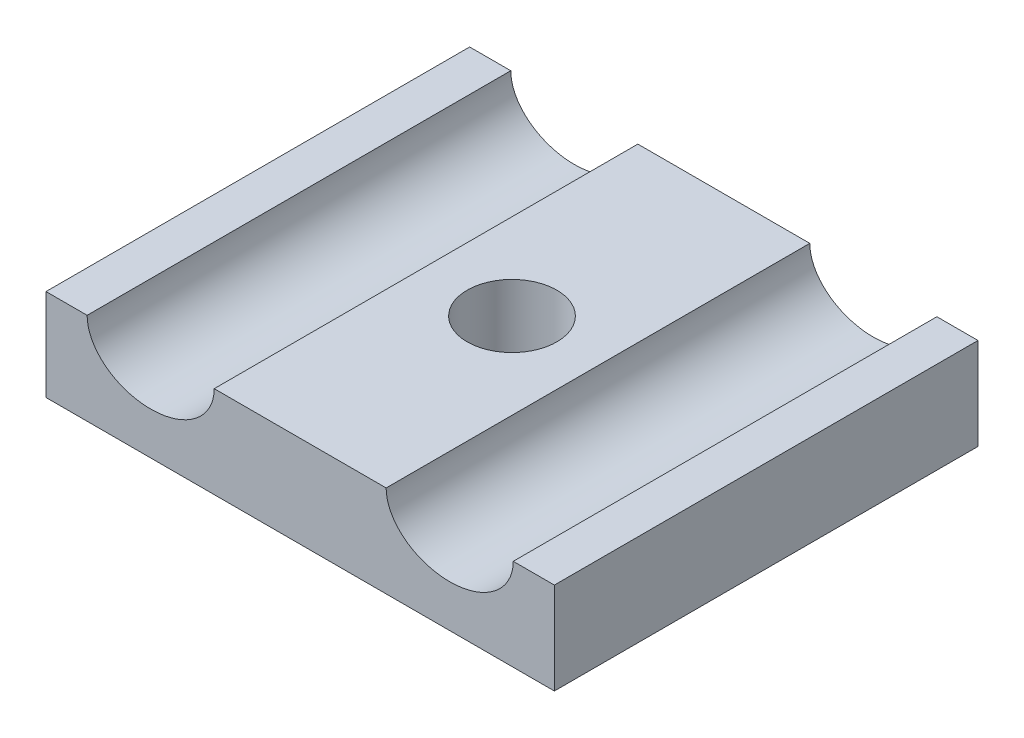
from build123d import *

# Parameters (mm, degrees)
SKETCH1_W           = 36
SKETCH1_H           = 30
BOSS_EXTRUDE1_DEPTH = 6.5
SKETCH2_R           = 3.175
CUT_EXTRUDE1_DEPTH  = 5
SKETCH3_RX          = 4.5
SKETCH3_RY          = 3.5
CUT_EXTRUDE3_DEPTH  = 30


with BuildPart() as part:
    # Sketch1 → Boss-Extrude1 (new body)
    with BuildSketch(Plane(origin=(0, 0, 0), x_dir=(1, 0, 0), z_dir=(0, 1, 0))):
        with Locations((-18, -15)):
            Rectangle(SKETCH1_W, SKETCH1_H)
    extrude(amount=BOSS_EXTRUDE1_DEPTH)

    # Sketch2 → Cut-Extrude1 (cut)
    with BuildSketch(Plane(origin=(0, 6.5, 0), x_dir=(1, 0, 0), z_dir=(0, 1, 0))):
        with Locations((-18, -15)):
            Circle(SKETCH2_R)
    extrude(amount=-CUT_EXTRUDE1_DEPTH, mode=Mode.SUBTRACT)

    # Sketch3 → Cut-Extrude3 (cut)
    with BuildSketch(Plane.XY.offset(30)):
        with Locations(Location((-7.4125, 6.5), (0, 0, -180))):
            Ellipse(SKETCH3_RX, SKETCH3_RY)
        with Locations(Location((-28.5875, 6.5), (0, 0, 0))):
            Ellipse(SKETCH3_RX, SKETCH3_RY)
    extrude(amount=-CUT_EXTRUDE3_DEPTH, mode=Mode.SUBTRACT)


solid = part.part
